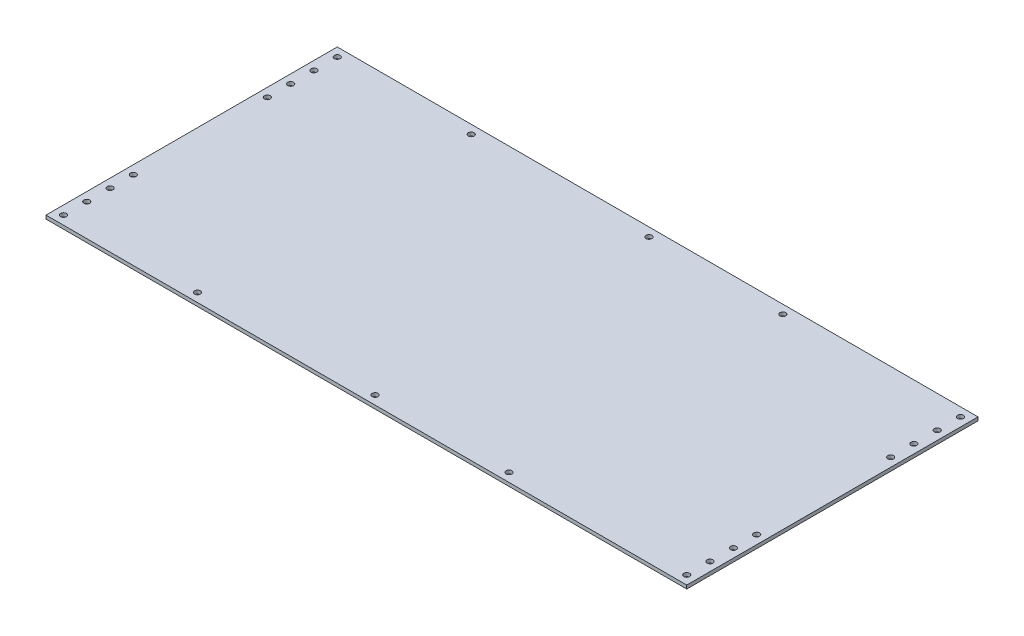
from build123d import *

# Parameters (mm, degrees)
SKETCH1_W           = 2200
SKETCH1_H           = 1000
SKETCH1_R           = 10
BOSS_EXTRUDE1_DEPTH = 12


with BuildPart() as part:
    # Sketch1 → Boss-Extrude1 (new body)
    with BuildSketch(Plane(origin=(0, 0, 0), x_dir=(1, 0, 0), z_dir=(0, 1, 0))):
        Rectangle(SKETCH1_W, SKETCH1_H)
        with Locations((-1070, 470)):
            Circle(SKETCH1_R, mode=Mode.SUBTRACT)
        with Locations((1070, 470)):
            Circle(SKETCH1_R, mode=Mode.SUBTRACT)
        with Locations((1070, 230)):
            Circle(SKETCH1_R, mode=Mode.SUBTRACT)
        with Locations((1070, 310)):
            Circle(SKETCH1_R, mode=Mode.SUBTRACT)
        with Locations((1070, 390)):
            Circle(SKETCH1_R, mode=Mode.SUBTRACT)
        with Locations((460, 470)):
            Circle(SKETCH1_R, mode=Mode.SUBTRACT)
        with Locations((0, 470)):
            Circle(SKETCH1_R, mode=Mode.SUBTRACT)
        with Locations((-610, 470)):
            Circle(SKETCH1_R, mode=Mode.SUBTRACT)
        with Locations((-1070, 390)):
            Circle(SKETCH1_R, mode=Mode.SUBTRACT)
        with Locations((-1070, 230)):
            Circle(SKETCH1_R, mode=Mode.SUBTRACT)
        with Locations((-1070, 310)):
            Circle(SKETCH1_R, mode=Mode.SUBTRACT)
        with Locations((1070, -230)):
            Circle(SKETCH1_R, mode=Mode.SUBTRACT)
        with Locations((1070, -310)):
            Circle(SKETCH1_R, mode=Mode.SUBTRACT)
        with Locations((1070, -390)):
            Circle(SKETCH1_R, mode=Mode.SUBTRACT)
        with Locations((1070, -470)):
            Circle(SKETCH1_R, mode=Mode.SUBTRACT)
        with Locations((460, -470)):
            Circle(SKETCH1_R, mode=Mode.SUBTRACT)
        with Locations((0, -470)):
            Circle(SKETCH1_R, mode=Mode.SUBTRACT)
        with Locations((-610, -470)):
            Circle(SKETCH1_R, mode=Mode.SUBTRACT)
        with Locations((-1070, -470)):
            Circle(SKETCH1_R, mode=Mode.SUBTRACT)
        with Locations((-1070, -390)):
            Circle(SKETCH1_R, mode=Mode.SUBTRACT)
        with Locations((-1070, -310)):
            Circle(SKETCH1_R, mode=Mode.SUBTRACT)
        with Locations((-1070, -230)):
            Circle(SKETCH1_R, mode=Mode.SUBTRACT)
    extrude(amount=-BOSS_EXTRUDE1_DEPTH)


solid = part.part
